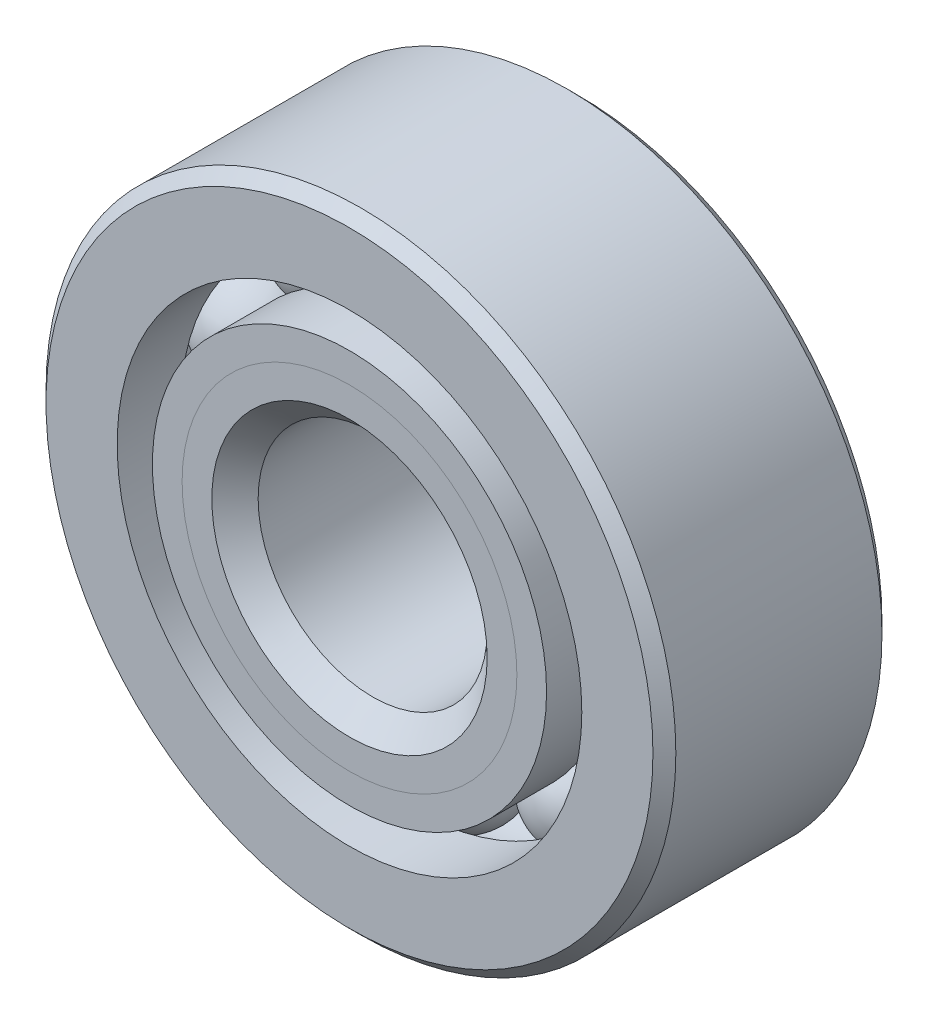
from build123d import *

# Parameters (mm, degrees)
CIRPATTERN1_COUNT = 10


with BuildPart() as part:
    # Sketch1 → Revolve1 (revolve)
    with BuildSketch(Plane(origin=(0, 0, 0), x_dir=(0, 0, -1), z_dir=(1, 0, 0))):
        with BuildLine():
            Line((2.8575, 8.73125), (-2.8575, 8.73125))
            Line((-2.8575, 8.73125), (-3.175, 8.41375))
            Line((-3.175, 8.41375), (-3.175, 6.441586538))
            Line((-3.175, 6.441586538), (-1.411111111, 6.441586538))
            ThreePointArc((-1.411111111, 6.441586538), (0, 7.446386277), (1.411111111, 6.441586538))
            Line((1.411111111, 6.441586538), (3.175, 6.441586538))
            Line((3.175, 6.441586538), (3.175, 8.41375))
            Line((3.175, 8.41375), (2.8575, 8.73125))
        make_face()
    revolve(axis=Axis((0, 0, 3.175), (0, 0, -1)))


with BuildPart() as body_2:
    # Sketch2 → Revolve2 (revolve)
    with BuildSketch(Plane(origin=(0, 0, 0), x_dir=(0, 0, -1), z_dir=(1, 0, 0))):
        with BuildLine():
            Line((-3.175, 5.464663462), (-1.411111111, 5.464663462))
            ThreePointArc((-1.411111111, 5.464663462), (-0.866149104, 4.73673075), (0, 4.459863723))
            Line((0, 4.459863723), (0, 3.817431861))
            Line((0, 3.817431861), (-2.3513842, 3.817431861))
            Line((-2.3513842, 3.817431861), (-3.175, 4.641047661))
            Line((-3.175, 4.641047661), (-3.175, 5.464663462))
        make_face()
    revolve(axis=Axis((0, 0, 3.175), (0, 0, -1)))


with BuildPart() as body_3:
    # Sketch3 → Revolve3 (revolve)
    with BuildSketch(Plane(origin=(0, 0, 0), x_dir=(0, 0, -1), z_dir=(1, 0, 0))):
        with BuildLine():
            Line((-3.175, 4.641047661), (-2.3513842, 3.817431861))
            Line((-2.3513842, 3.817431861), (0, 3.817431861))
            Line((0, 3.817431861), (0, 4.459863723))
            ThreePointArc((0, 4.459863723), (0.866149104, 4.73673075), (1.411111111, 5.464663462))
            Line((1.411111111, 5.464663462), (3.175, 5.464663462))
            Line((3.175, 5.464663462), (3.175, 3.4925))
            Line((3.175, 3.4925), (2.8575, 3.175))
            Line((2.8575, 3.175), (-2.532568139, 3.175))
            Line((-2.532568139, 3.175), (-3.175, 3.817431861))
            Line((-3.175, 3.817431861), (-3.175, 4.641047661))
        make_face()
    revolve(axis=Axis((0, 0, 3.175), (0, 0, -1)))


with BuildPart() as body_4:
    # Sketch4 → Revolve4 (revolve)
    with BuildSketch(Plane(origin=(0, 0, 0), x_dir=(0, 0, -1), z_dir=(1, 0, 0))):
        with BuildLine():
            Line((-1.493261277, 5.953125), (1.493261277, 5.953125))
            ThreePointArc((1.493261277, 5.953125), (0, 7.446386277), (-1.493261277, 5.953125))
        make_face()
    revolve(axis=Axis((0, 5.953125, 1.493261277), (0, 0, -1)))


with BuildPart() as cirpattern1_1:
    # CirPattern1: pattern copy
    add(body_4.part.rotate(Axis((0, 0, -3.175), (0, 0, 1)), 1 * 360 / CIRPATTERN1_COUNT))


with BuildPart() as cirpattern1_2:
    # CirPattern1: pattern copy
    add(body_4.part.rotate(Axis((0, 0, -3.175), (0, 0, 1)), 2 * 360 / CIRPATTERN1_COUNT))


with BuildPart() as cirpattern1_3:
    # CirPattern1: pattern copy
    add(body_4.part.rotate(Axis((0, 0, -3.175), (0, 0, 1)), 3 * 360 / CIRPATTERN1_COUNT))


with BuildPart() as cirpattern1_4:
    # CirPattern1: pattern copy
    add(body_4.part.rotate(Axis((0, 0, -3.175), (0, 0, 1)), 4 * 360 / CIRPATTERN1_COUNT))


with BuildPart() as cirpattern1_5:
    # CirPattern1: pattern copy
    add(body_4.part.rotate(Axis((0, 0, -3.175), (0, 0, 1)), 5 * 360 / CIRPATTERN1_COUNT))


with BuildPart() as cirpattern1_6:
    # CirPattern1: pattern copy
    add(body_4.part.rotate(Axis((0, 0, -3.175), (0, 0, 1)), 6 * 360 / CIRPATTERN1_COUNT))


with BuildPart() as cirpattern1_7:
    # CirPattern1: pattern copy
    add(body_4.part.rotate(Axis((0, 0, -3.175), (0, 0, 1)), 7 * 360 / CIRPATTERN1_COUNT))


with BuildPart() as cirpattern1_8:
    # CirPattern1: pattern copy
    add(body_4.part.rotate(Axis((0, 0, -3.175), (0, 0, 1)), 8 * 360 / CIRPATTERN1_COUNT))


with BuildPart() as cirpattern1_9:
    # CirPattern1: pattern copy
    add(body_4.part.rotate(Axis((0, 0, -3.175), (0, 0, 1)), 9 * 360 / CIRPATTERN1_COUNT))


solid = Compound([part.part, body_2.part, body_3.part, body_4.part, cirpattern1_1.part, cirpattern1_2.part, cirpattern1_3.part, cirpattern1_4.part, cirpattern1_5.part, cirpattern1_6.part, cirpattern1_7.part, cirpattern1_8.part, cirpattern1_9.part])
